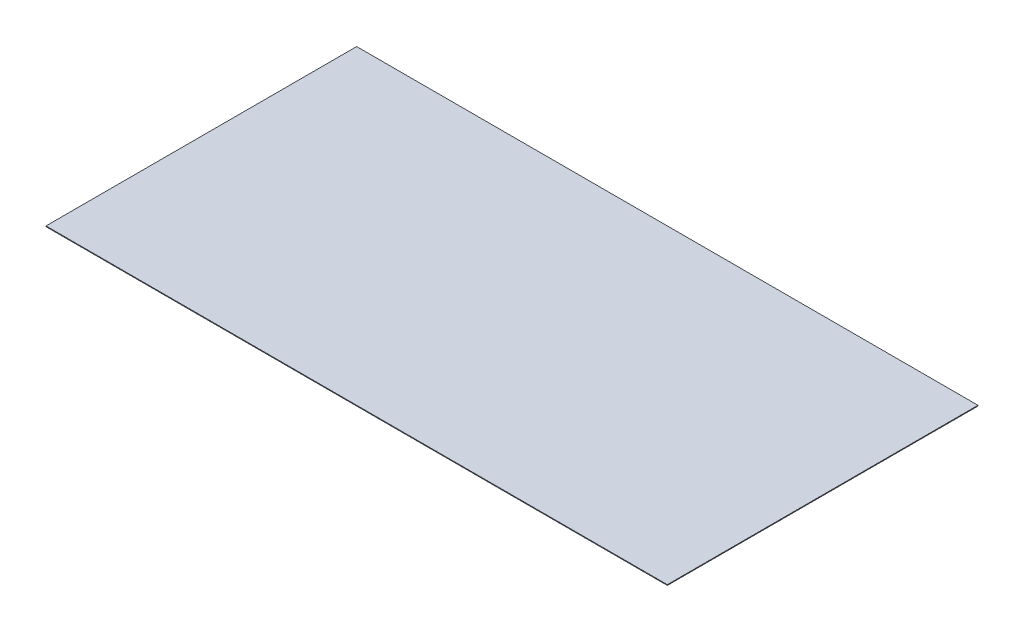
from build123d import *

# Parameters (mm, degrees)
SKETCH1_W           = 900
SKETCH1_H           = 450
BOSS_EXTRUDE1_DEPTH = 1


with BuildPart() as part:
    # Sketch1 → Boss-Extrude1 (new body)
    with BuildSketch(Plane(origin=(0, 0, 0), x_dir=(1, 0, 0), z_dir=(0, 1, 0))):
        Rectangle(SKETCH1_W, SKETCH1_H)
    extrude(amount=BOSS_EXTRUDE1_DEPTH)


solid = part.part
